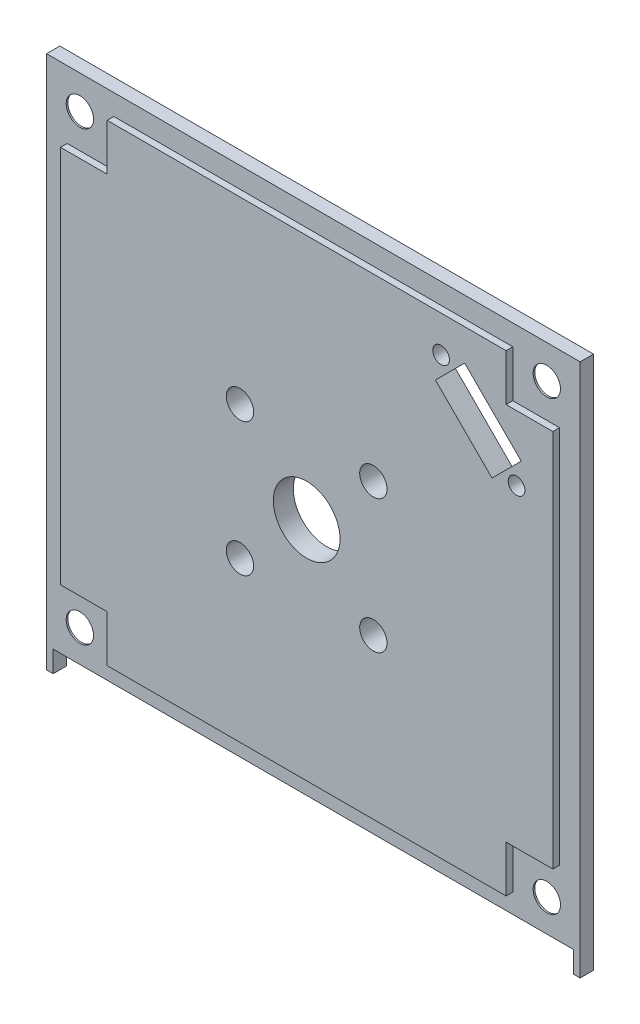
from build123d import *

# Parameters (mm, degrees)
ESQUISSE1_W             = 80
ESQUISSE1_H             = 80
BOSS_EXTRU_1_DEPTH      = 2
BOSS_EXTRU_2_DEPTH      = 1
ESQUISSE3_R             = 2.05
ESQUISSE3_W             = 78
ESQUISSE3_H             = 3.2
ENL_V_MAT_EXTRU_1_DEPTH = 3
ESQUISSE4_R             = 5
ESQUISSE4_R_2           = 2.05
ENL_V_MAT_EXTRU_2_DEPTH = 4
CHANFREIN1_SIZE         = 1.75
CHANFREIN1_SIZE2        = 2.594481695
CHANFREIN1_PART_2_SIZE  = 1.75
CHANFREIN1_PART_2_SIZE2 = 2.594481695
CHANFREIN1_PART_3_SIZE  = 1.75
CHANFREIN1_PART_3_SIZE2 = 2.594481695
CHANFREIN1_PART_4_SIZE  = 1.75
CHANFREIN1_PART_4_SIZE2 = 2.594481695
ENL_V_MAT_EXTRU_3_DEPTH = 1
ESQUISSE8_R             = 1.25
ENL_V_MAT_EXTRU_4_DEPTH = 3


with BuildPart() as part:
    # Esquisse1 → Boss.-Extru.1 (new body)
    with BuildSketch(Plane.XY):
        with Locations((40, 40)):
            Rectangle(ESQUISSE1_W, ESQUISSE1_H)
    extrude(amount=BOSS_EXTRU_1_DEPTH)

    # Esquisse2 → Boss.-Extru.2 (add)
    with BuildSketch(Plane.XY.offset(2)):
        Polygon((10.1, 6.1), (10.1, 13.1), (3.1, 13.1), (3.1, 69.9), (10.1, 69.9), (10.1, 76.9), (69.9, 76.9), (69.9, 69.9), (76.9, 69.9), (76.9, 13.1), (69.9, 13.1), (69.9, 6.1), align=None)
    extrude(amount=BOSS_EXTRU_2_DEPTH)

    # Esquisse3 → Enlèv. mat.-Extru.1 (cut, through all)
    with BuildSketch(Plane.XY.offset(2)):
        with Locations((5, 75)):
            Circle(ESQUISSE3_R)
        with Locations((75, 75)):
            Circle(ESQUISSE3_R)
        with Locations((75, 8)):
            Circle(ESQUISSE3_R)
        with Locations((5, 8)):
            Circle(ESQUISSE3_R)
        with Locations((40, 1.6)):
            Rectangle(ESQUISSE3_W, ESQUISSE3_H)
    extrude(amount=-ENL_V_MAT_EXTRU_1_DEPTH, mode=Mode.SUBTRACT)

    # Esquisse4 → Enlèv. mat.-Extru.2 (cut, through all)
    with BuildSketch(Plane.XY.offset(3)):
        with Locations((40, 40)):
            Circle(ESQUISSE4_R)
        with Locations((30, 50)):
            Circle(ESQUISSE4_R_2)
        with Locations((30, 30)):
            Circle(ESQUISSE4_R_2)
        with Locations((50, 30)):
            Circle(ESQUISSE4_R_2)
        with Locations((50, 50)):
            Circle(ESQUISSE4_R_2)
    extrude(amount=-ENL_V_MAT_EXTRU_2_DEPTH, mode=Mode.SUBTRACT)

    # Chanfrein1
    chanfrein1_edges = [part.edges().sort_by_distance(p)[0] for p in [
        (2.95, 75, 0),
    ]]
    chanfrein1_side = [part.faces().sort_by_distance(p)[0] for p in [
        (2.95, 75, 1),
    ]]
    chamfer(chanfrein1_edges, length=CHANFREIN1_SIZE, length2=CHANFREIN1_SIZE2, reference=chanfrein1_side[0])

    # Chanfrein1 part 2
    chanfrein1_part_2_edges = [part.edges().sort_by_distance(p)[0] for p in [
        (72.95, 75, 0),
    ]]
    chanfrein1_part_2_side = [part.faces().sort_by_distance(p)[0] for p in [
        (72.95, 75, 1),
    ]]
    chamfer(chanfrein1_part_2_edges, length=CHANFREIN1_PART_2_SIZE, length2=CHANFREIN1_PART_2_SIZE2, reference=chanfrein1_part_2_side[0])

    # Chanfrein1 part 3
    chanfrein1_part_3_edges = [part.edges().sort_by_distance(p)[0] for p in [
        (72.95, 8, 0),
    ]]
    chanfrein1_part_3_side = [part.faces().sort_by_distance(p)[0] for p in [
        (72.95, 8, 1),
    ]]
    chamfer(chanfrein1_part_3_edges, length=CHANFREIN1_PART_3_SIZE, length2=CHANFREIN1_PART_3_SIZE2, reference=chanfrein1_part_3_side[0])

    # Chanfrein1 part 4
    chanfrein1_part_4_edges = [part.edges().sort_by_distance(p)[0] for p in [
        (2.95, 8, 0),
    ]]
    chanfrein1_part_4_side = [part.faces().sort_by_distance(p)[0] for p in [
        (2.95, 8, 1),
    ]]
    chamfer(chanfrein1_part_4_edges, length=CHANFREIN1_PART_4_SIZE, length2=CHANFREIN1_PART_4_SIZE2, reference=chanfrein1_part_4_side[0])

    # Esquisse6 → Enlèv. mat.-Extru.3 (cut)
    with BuildSketch(Plane(origin=(0, 0, 0), x_dir=(-1, 0, 0), z_dir=(0, 0, -1))):
        Polygon((-70.615937957, 56.473802333), (-56.473802333, 70.615937957), (-60.857864376, 75), (-75, 60.857864376), align=None)
    extrude(amount=-ENL_V_MAT_EXTRU_3_DEPTH, mode=Mode.SUBTRACT)

    # Esquisse8 → Enlèv. mat.-Extru.4 (cut, through all)
    with BuildSketch(Plane(origin=(0, 0, 1), x_dir=(-1, 0, 0), z_dir=(0, 0, -1))):
        with Locations((-60.150757595, 71.464466094)):
            Circle(ESQUISSE8_R)
        with Locations((-71.464466094, 60.150757595)):
            Circle(ESQUISSE8_R)
        Polygon((-67.787510832, 59.302229458), (-72.171572875, 63.686291501), (-63.686291501, 72.171572875), (-59.302229458, 67.787510832), align=None)
    extrude(amount=-ENL_V_MAT_EXTRU_4_DEPTH, mode=Mode.SUBTRACT)


solid = part.part
